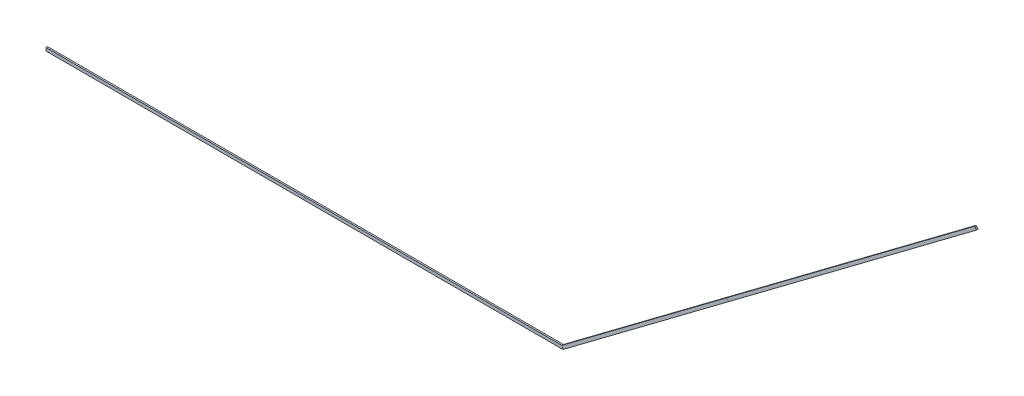
from build123d import *

# Parameters (mm, degrees)
SKETCH2_W            = 15
SKETCH2_H            = 30
BOSS_EXTRUDE1_DEPTH  = 2500
BOSS_EXTRUDE9_START  = 2500
SKETCH2_11_W         = 15
SKETCH2_11_H         = 30
BOSS_EXTRUDE9_DEPTH  = 2500
SKETCH3_W            = 15
SKETCH3_H            = 30
BOSS_EXTRUDE8_DEPTH  = 2000
BOSS_EXTRUDE10_START = 2000
SKETCH3_2_W          = 15
SKETCH3_2_H          = 30
BOSS_EXTRUDE10_DEPTH = 3000


with BuildPart() as part:
    # Sketch2 → Boss-Extrude1 (new body)
    with BuildSketch(Plane(origin=(0, 0, 0), x_dir=(0, 0, -1), z_dir=(1, 0, 0))):
        Rectangle(SKETCH2_W, SKETCH2_H)
    extrude(amount=BOSS_EXTRUDE1_DEPTH)


with BuildPart() as body_2:
    # Sketch2_11 → Boss-Extrude9 (new body)
    with BuildSketch(Plane(origin=(0, 0, 0), x_dir=(0, 0, -1), z_dir=(1, 0, 0)).offset(BOSS_EXTRUDE9_START)):
        Rectangle(SKETCH2_11_W, SKETCH2_11_H)
    extrude(amount=BOSS_EXTRUDE9_DEPTH)


with BuildPart() as body_3:
    # Sketch3 → Boss-Extrude8 (new body)
    with BuildSketch(Plane(origin=(5000, 0, 0), x_dir=(0, 0, -1), z_dir=(0.8, 0.6, 0))):
        Rectangle(SKETCH3_W, SKETCH3_H)
    extrude(amount=BOSS_EXTRUDE8_DEPTH)


with BuildPart() as body_4:
    # Sketch3_2 → Boss-Extrude10 (new body)
    with BuildSketch(Plane(origin=(5000, 0, 0), x_dir=(0, 0, -1), z_dir=(0.8, 0.6, 0)).offset(BOSS_EXTRUDE10_START)):
        Rectangle(SKETCH3_2_W, SKETCH3_2_H)
    extrude(amount=BOSS_EXTRUDE10_DEPTH)


solid = Compound([part.part, body_2.part, body_3.part, body_4.part])
